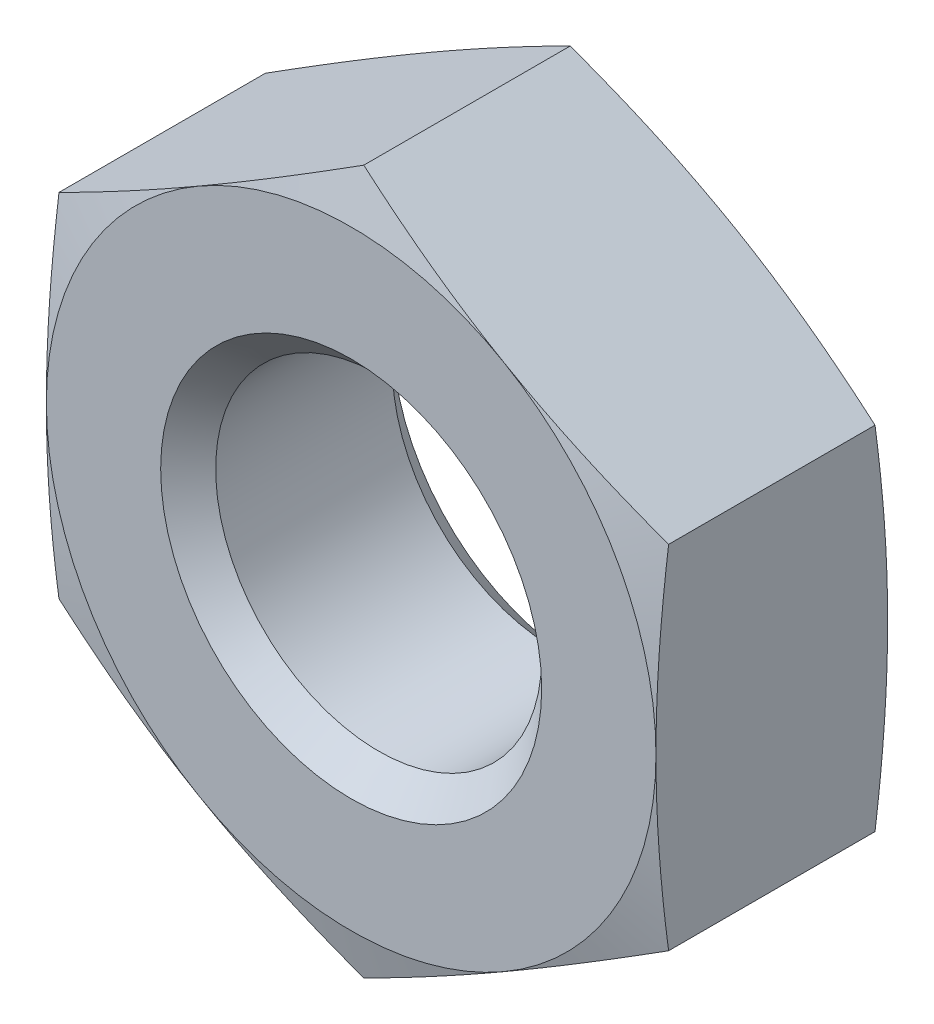
from build123d import *

# Parameters (mm, degrees)
SKETCH2_W          = 25.4
SKETCH2_H          = 25.4
CUT_EXTRUDE1_DEPTH = 4.826


with BuildPart() as part:
    # Sketch1 → Revolve1 (revolve)
    with BuildSketch(Plane(origin=(0, 0, 0), x_dir=(0, 0, -1), z_dir=(1, 0, 0))):
        Polygon((0, 0), (0, 6.35), (0.340295474, 7.62), (4.485704526, 7.62), (4.826, 6.35), (4.826, 0), align=None)
    revolve(axis=Axis((0, 0, -4.826), (0, 0, 1)))

    # Sketch2 → Cut-Extrude1 (cut)
    with BuildSketch(Plane.XY):
        Rectangle(SKETCH2_W, SKETCH2_H)
        Polygon((-6.35, 3.666174209), (-6.35, -3.666174209), (0, -7.332348419), (6.35, -3.666174209), (6.35, 3.666174209), (0, 7.332348419), align=None, mode=Mode.SUBTRACT)
    extrude(amount=-CUT_EXTRUDE1_DEPTH, mode=Mode.SUBTRACT)

    # Sketch3 → Cut-Revolve1 (revolve, cut)
    with BuildSketch(Plane(origin=(0, 0, 0), x_dir=(0, 0, -1), z_dir=(1, 0, 0))):
        Polygon((0, 0), (0, 3.96875), (0.57277, 3.39598), (4.25323, 3.39598), (4.826, 3.96875), (4.826, 0), align=None)
    revolve(axis=Axis((0, 0, -4.826), (0, 0, 1)), mode=Mode.SUBTRACT)


solid = part.part
